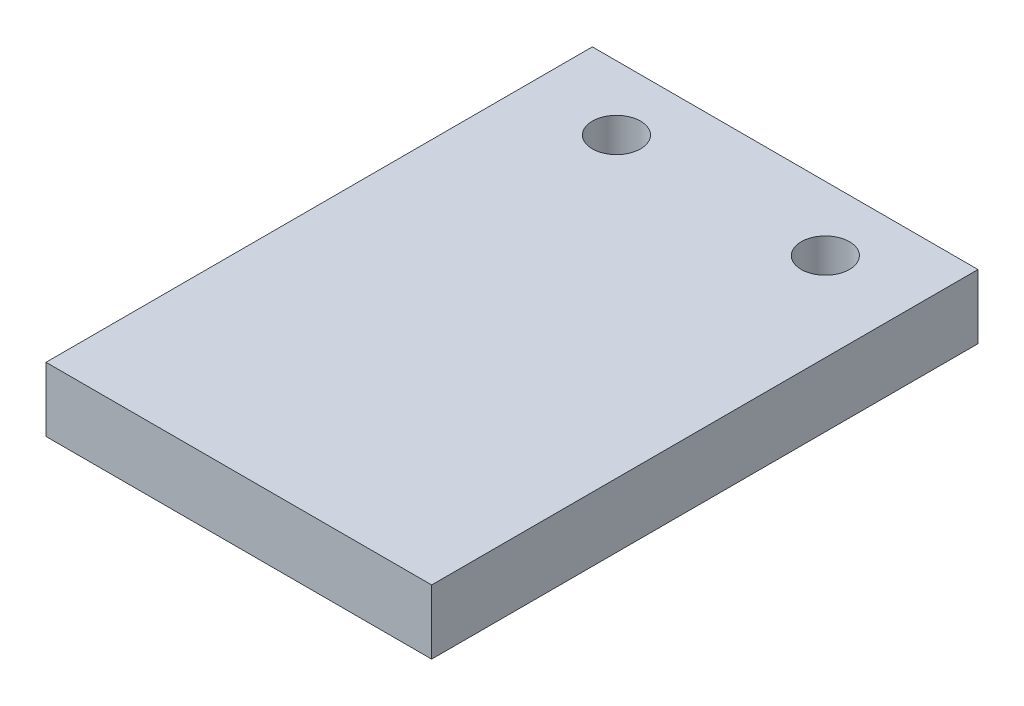
from build123d import *

# Parameters (mm, degrees)
SKETCH1_W           = 76.2
SKETCH1_H           = 107.95
SKETCH1_R           = 4.7625
BOSS_EXTRUDE1_DEPTH = 12.7


with BuildPart() as part:
    # Sketch1 → Boss-Extrude1 (new body)
    with BuildSketch(Plane(origin=(0, 0, 0), x_dir=(1, 0, 0), z_dir=(0, 1, 0))):
        with Locations((20.6375, -41.275)):
            Rectangle(SKETCH1_W, SKETCH1_H)
        Circle(SKETCH1_R, mode=Mode.SUBTRACT)
        with Locations((41.275, 0)):
            Circle(SKETCH1_R, mode=Mode.SUBTRACT)
    extrude(amount=BOSS_EXTRUDE1_DEPTH)


solid = part.part
